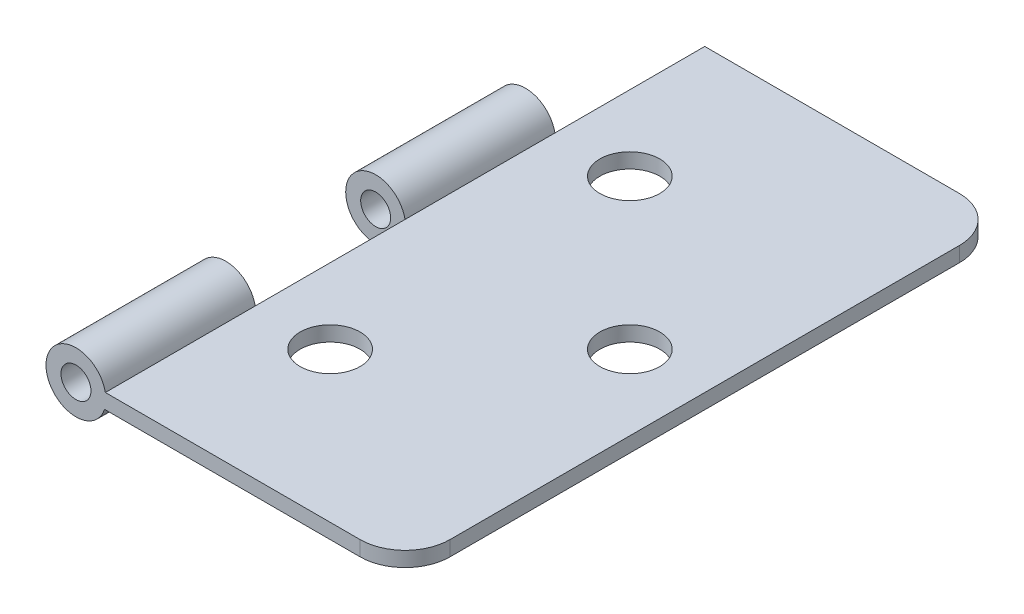
from build123d import *

# Parameters (mm, degrees)
BOSS_EXTRUDE2_DEPTH = 40
SKETCH3_4_R         = 1
BOSS_EXTRUDE3_DEPTH = 10
BOSS_EXTRUDE4_START = -20
SKETCH3_5_R         = 1
BOSS_EXTRUDE4_DEPTH = 10
SKETCH5_R           = 2
CUT_EXTRUDE1_DEPTH  = 10
FILLET1_R           = 3
FILLET2_R           = 3


with BuildPart() as part:
    # Sketch3 → Boss-Extrude2 (new body)
    with BuildSketch(Plane.XY):
        with BuildLine():
            Line((14.107916892, 0), (14.107916892, 1))
            Line((14.107916892, 1), (-5.892083108, 1))
            ThreePointArc((-5.892083108, 1), (-5.863018057, 0.804975408), (-5.853298215, 0.608036602))
            ThreePointArc((-5.853298215, 0.608036602), (-5.877106832, 0.300355571), (-5.947965831, 0))
            Line((-5.947965831, 0), (14.107916892, 0))
        make_face()
    extrude(amount=-BOSS_EXTRUDE2_DEPTH)

    # Sketch3_4 → Boss-Extrude3 (add)
    with BuildSketch(Plane.XY):
        with BuildLine():
            ThreePointArc((-5.853298215, 0.608036602), (-5.863018057, 0.804975408), (-5.892083108, 1))
            ThreePointArc((-5.892083108, 1), (-9.850182631, 0.719627941), (-5.947965831, 0))
            ThreePointArc((-5.947965831, 0), (-5.877106832, 0.300355571), (-5.853298215, 0.608036602))
        make_face()
        with Locations((-7.853298215, 0.608036602)):
            Circle(SKETCH3_4_R, mode=Mode.SUBTRACT)
    extrude(amount=-BOSS_EXTRUDE3_DEPTH)

    # Sketch3_5 → Boss-Extrude4 (add)
    with BuildSketch(Plane.XY.offset(BOSS_EXTRUDE4_START)):
        with BuildLine():
            ThreePointArc((-5.853298215, 0.608036602), (-5.863018057, 0.804975408), (-5.892083108, 1))
            ThreePointArc((-5.892083108, 1), (-9.850182631, 0.719627941), (-5.947965831, 0))
            ThreePointArc((-5.947965831, 0), (-5.877106832, 0.300355571), (-5.853298215, 0.608036602))
        make_face()
        with Locations((-7.853298215, 0.608036602)):
            Circle(SKETCH3_5_R, mode=Mode.SUBTRACT)
    extrude(amount=-BOSS_EXTRUDE4_DEPTH)

    # Sketch5 → Cut-Extrude1 (cut)
    with BuildSketch(Plane(origin=(0, 1, 0), x_dir=(1, 0, 0), z_dir=(0, 1, 0))):
        with Locations((-0.892083108, 30)):
            Circle(SKETCH5_R)
        with Locations((-0.892083108, 10)):
            Circle(SKETCH5_R)
        with Locations((9.107916892, 20)):
            Circle(SKETCH5_R)
    extrude(amount=-CUT_EXTRUDE1_DEPTH, mode=Mode.SUBTRACT)

    # Fillet1
    fillet1_edges = [part.edges().sort_by_distance(p)[0] for p in [
        (14.107916892, 0.5, -40),
    ]]
    fillet(fillet1_edges, radius=FILLET1_R)

    # Fillet2
    fillet2_edges = [part.edges().sort_by_distance(p)[0] for p in [
        (14.107916892, 0.5, 0),
    ]]
    fillet(fillet2_edges, radius=FILLET2_R)


solid = part.part
